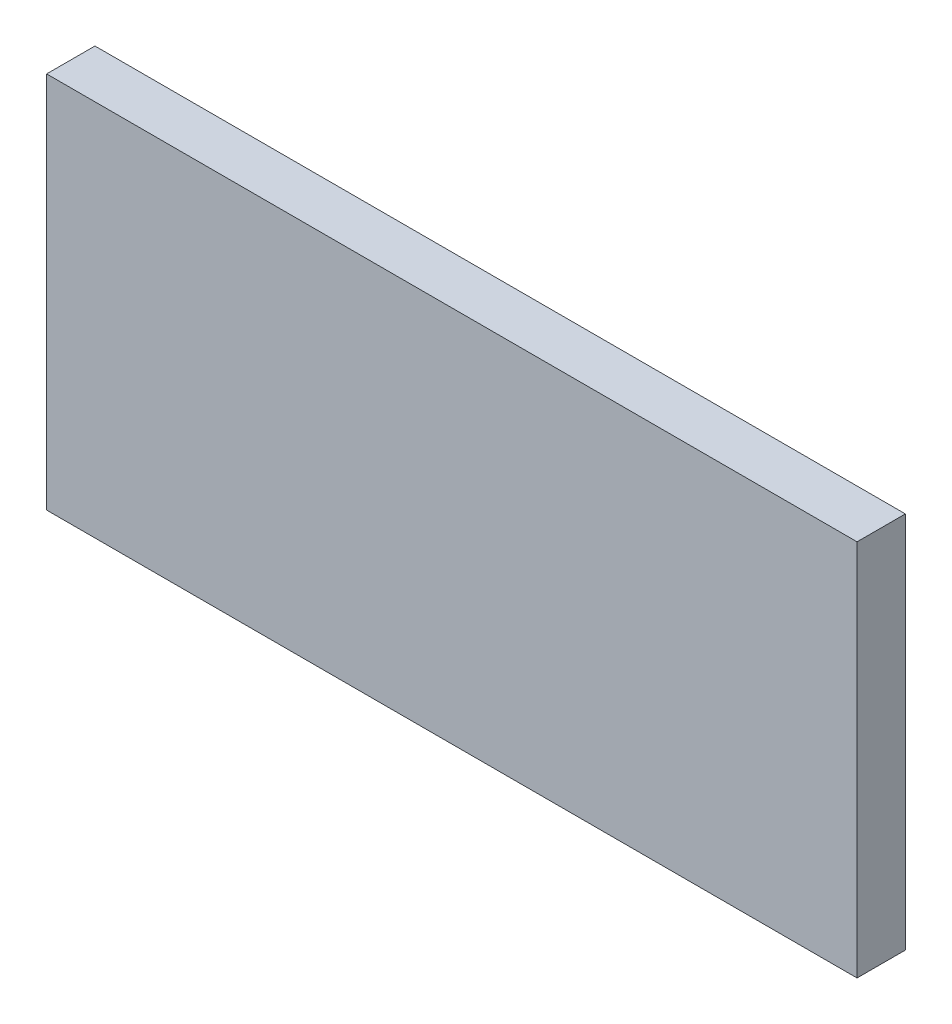
from build123d import *

# Parameters (mm, degrees)
ESQUISSE1_W        = 369
ESQUISSE1_H        = 172
BOSS_EXTRU_1_DEPTH = 22


with BuildPart() as part:
    # Esquisse1 → Boss.-Extru.1 (new body)
    with BuildSketch(Plane.XY):
        Rectangle(ESQUISSE1_W, ESQUISSE1_H)
    extrude(amount=BOSS_EXTRU_1_DEPTH)


solid = part.part
